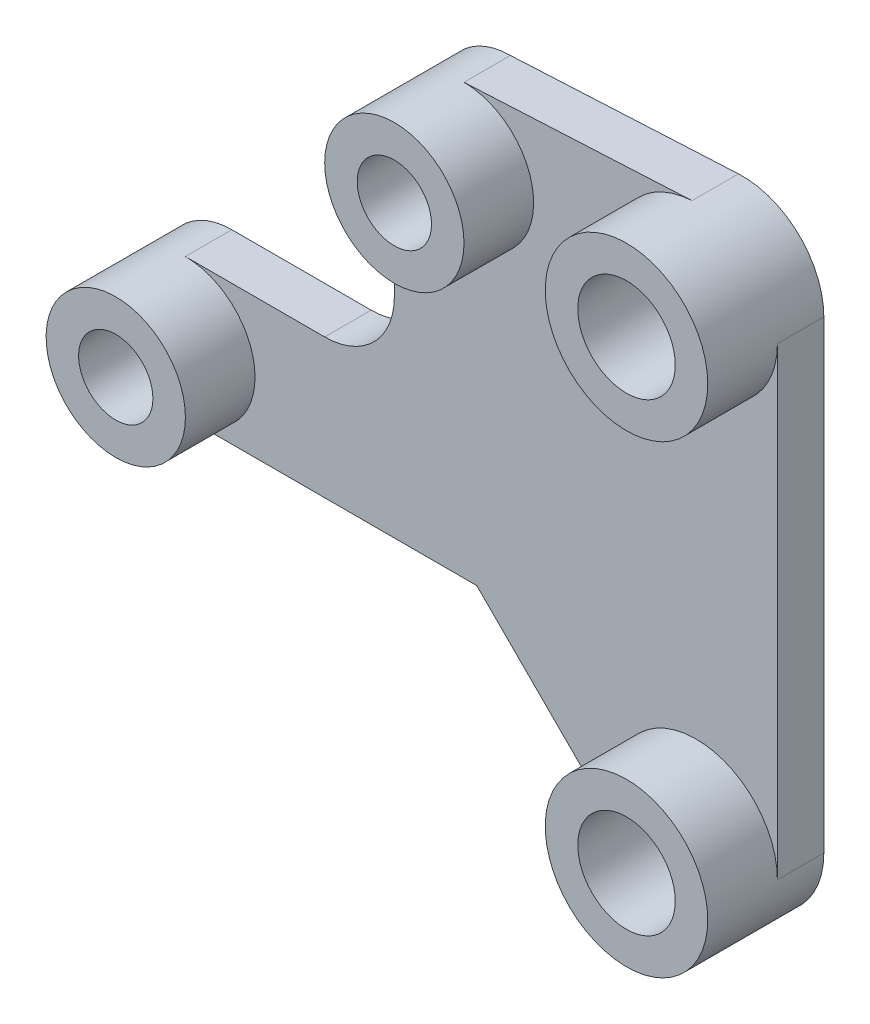
from build123d import *

# Parameters (mm, degrees)
BOSS_EXTRUDE1_DEPTH = 2
SKETCH2_R           = 3
SKETCH2_R_2         = 3.5
BOSS_EXTRUDE2_DEPTH = 3
SKETCH3_R           = 1.6
SKETCH3_R_2         = 2.1
CUT_EXTRUDE1_DEPTH  = 6


with BuildPart() as part:
    # Sketch1 → Boss-Extrude1 (new body)
    with BuildSketch(Plane.XY):
        with BuildLine():
            Line((0, 3), (6, 3))
            ThreePointArc((6, 3), (8.121320344, 3.878679656), (9, 6))
            Line((9, 6), (9, 12.5))
            ThreePointArc((9, 12.5), (9.878679656, 14.621320344), (12, 15.5))
            Line((12, 15.5), (21.823666576, 15.995555253))
            ThreePointArc((21.823666576, 15.995555253), (24.411724799, 15.036450964), (25.5, 12.5))
            Line((25.5, 12.5), (25.5, -7.5))
            ThreePointArc((25.5, -7.5), (23.339392013, -10.733578364), (19.525126266, -9.974873734))
            Line((19.525126266, -9.974873734), (12.550252532, -3))
            Line((12.550252532, -3), (0, -3))
            ThreePointArc((0, -3), (-3, 0), (0, 3))
        make_face()
    extrude(amount=BOSS_EXTRUDE1_DEPTH)

    # Sketch2 → Boss-Extrude2 (add)
    with BuildSketch(Plane.XY.offset(2)):
        Circle(SKETCH2_R)
        with Locations((12, 12.5)):
            Circle(SKETCH2_R)
        with Locations((22, 12.5)):
            Circle(SKETCH2_R_2)
        with Locations((22, -7.5)):
            Circle(SKETCH2_R_2)
    extrude(amount=BOSS_EXTRUDE2_DEPTH)

    # Sketch3 → Cut-Extrude1 (cut, through all)
    with BuildSketch(Plane.XY.offset(5)):
        Circle(SKETCH3_R)
        with Locations((12, 12.5)):
            Circle(SKETCH3_R)
        with Locations((22, 12.5)):
            Circle(SKETCH3_R_2)
        with Locations((22, -7.5)):
            Circle(SKETCH3_R_2)
    extrude(amount=-CUT_EXTRUDE1_DEPTH, mode=Mode.SUBTRACT)


solid = part.part
